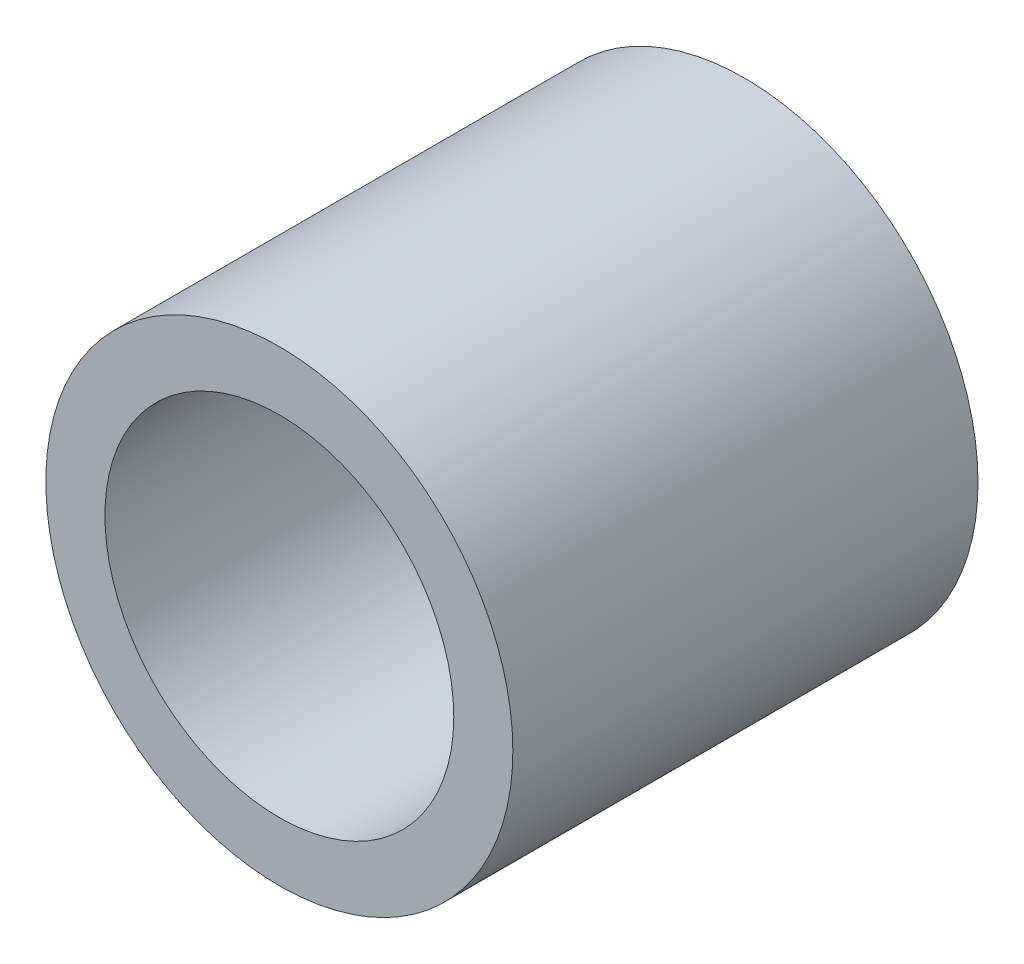
from build123d import *

# Parameters (mm, degrees)
SKETCH1_R      = 3.1877
SKETCH1_R_2    = 2.38125
EXTRUDE1_DEPTH = 3.175


with BuildPart() as part:
    # Sketch1 → Extrude1 (new body, symmetric)
    with BuildSketch(Plane.XY):
        Circle(SKETCH1_R)
        Circle(SKETCH1_R_2, mode=Mode.SUBTRACT)
    extrude(amount=EXTRUDE1_DEPTH, both=True)


solid = part.part
